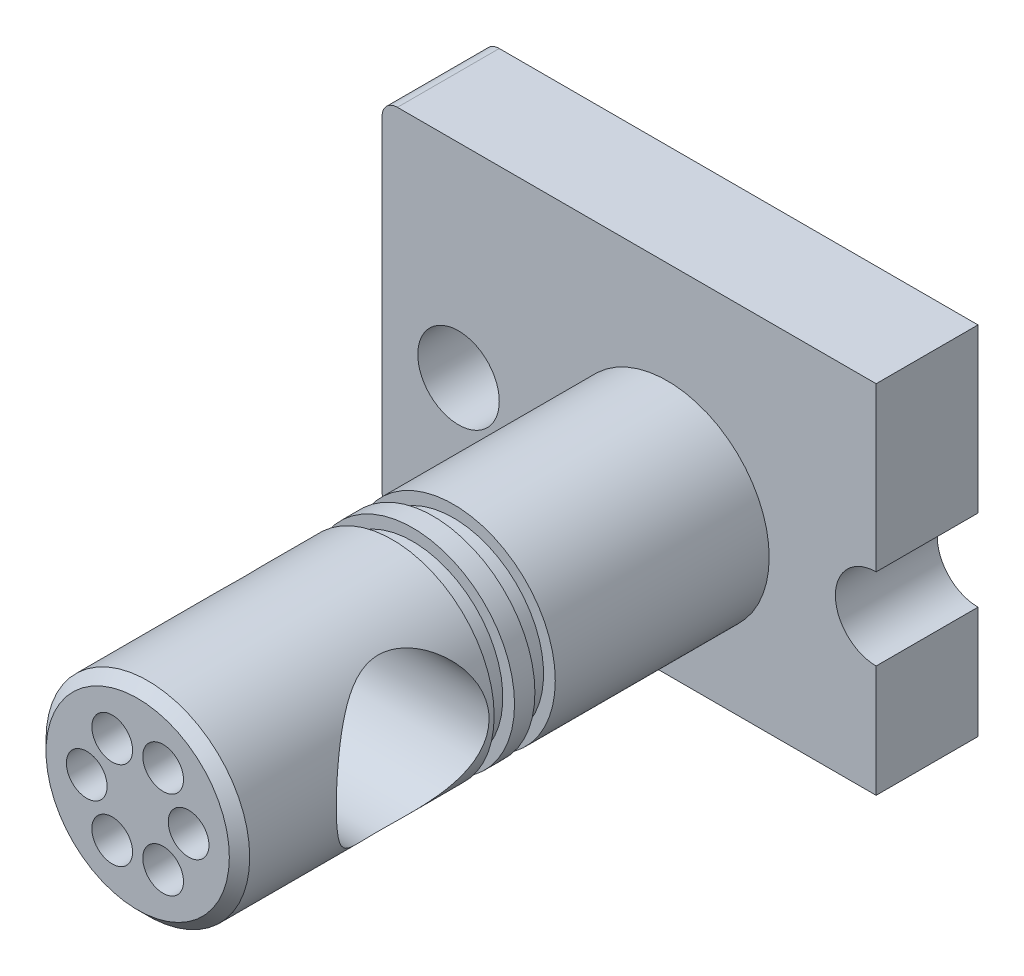
from build123d import *

# Parameters (mm, degrees)
SKETCH1_R               = 8
BOSS_EXTRUDE1_DEPTH     = 20
SKETCH2_R               = 20
BOSS_EXTRUDE2_DEPTH     = 104
SKETCH3_R               = 15
CUT_EXTRUDE1_DEPTH      = 42
CUT_EXTRUDE1_DEPTH_BACK = 57
SKETCH4_W               = 4
SKETCH4_H               = 2.3
SKETCH5_R               = 4
CUT_EXTRUDE2_DEPTH      = 30
CIRPATTERN1_COUNT       = 6
FILLET1_R               = 3
CHAMFER1_SIZE           = 2


with BuildPart() as part:
    # Sketch1 → Boss-Extrude1 (new body)
    with BuildSketch(Plane.XY):
        with BuildLine():
            Line((41, -8), (41, -30))
            Line((41, -30), (-56, -30))
            Line((-56, -30), (-56, 40))
            Line((-56, 40), (41, 40))
            Line((41, 40), (41, 8))
            ThreePointArc((41, 8), (33, 0), (41, -8))
        make_face()
        with Locations((-41, 0)):
            Circle(SKETCH1_R, mode=Mode.SUBTRACT)
    extrude(amount=BOSS_EXTRUDE1_DEPTH)

    # Sketch2 → Boss-Extrude2 (add)
    with BuildSketch(Plane.XY.offset(20)):
        Circle(SKETCH2_R)
    extrude(amount=BOSS_EXTRUDE2_DEPTH)

    # Sketch3 → Cut-Extrude1 (cut, two sides)
    with BuildSketch(Plane(origin=(0, 0, 0), x_dir=(0, 0, -1), z_dir=(1, 0, 0))) as cut_extrude1_sk:
        with Locations((-90, 0)):
            Circle(SKETCH3_R)
    extrude(amount=CUT_EXTRUDE1_DEPTH, mode=Mode.SUBTRACT)
    extrude(cut_extrude1_sk.sketch, amount=-CUT_EXTRUDE1_DEPTH_BACK, mode=Mode.SUBTRACT)

    # Sketch4 → Cut-Revolve1 (revolve, cut)
    with BuildSketch(Plane(origin=(0, 0, 0), x_dir=(0, 0, -1), z_dir=(1, 0, 0))):
        with Locations((-72, 18.85)):
            Rectangle(SKETCH4_W, SKETCH4_H)
        with Locations((-64, 18.85)):
            Rectangle(SKETCH4_W, SKETCH4_H)
    revolve(axis=Axis((0, 0, 0), (0, 0, 1)), mode=Mode.SUBTRACT)

    # Sketch5 → Cut-Extrude2 (cut)
    with BuildSketch(Plane.XY.offset(124)):
        with Locations((10, 0)):
            Circle(SKETCH5_R)
    cut_extrude2 = extrude(amount=-CUT_EXTRUDE2_DEPTH, mode=Mode.SUBTRACT)

    # CirPattern1: Cut-Extrude2 ×6 about axis
    cirpattern1_axis = Axis((0, 0, 0), (0, 0, 1))
    for i in range(1, CIRPATTERN1_COUNT):
        add(cut_extrude2.rotate(cirpattern1_axis, i * 360 / CIRPATTERN1_COUNT), mode=Mode.SUBTRACT)

    # Fillet1
    fillet1_edges = [part.edges().sort_by_distance(p)[0] for p in [
        (-56, -30, 10),
        (-56, 40, 10),
    ]]
    fillet(fillet1_edges, radius=FILLET1_R)

    # Chamfer1
    chamfer1_edges = [part.edges().sort_by_distance(p)[0] for p in [
        (-20, 0, 124),
    ]]
    chamfer(chamfer1_edges, length=CHAMFER1_SIZE)


solid = part.part
